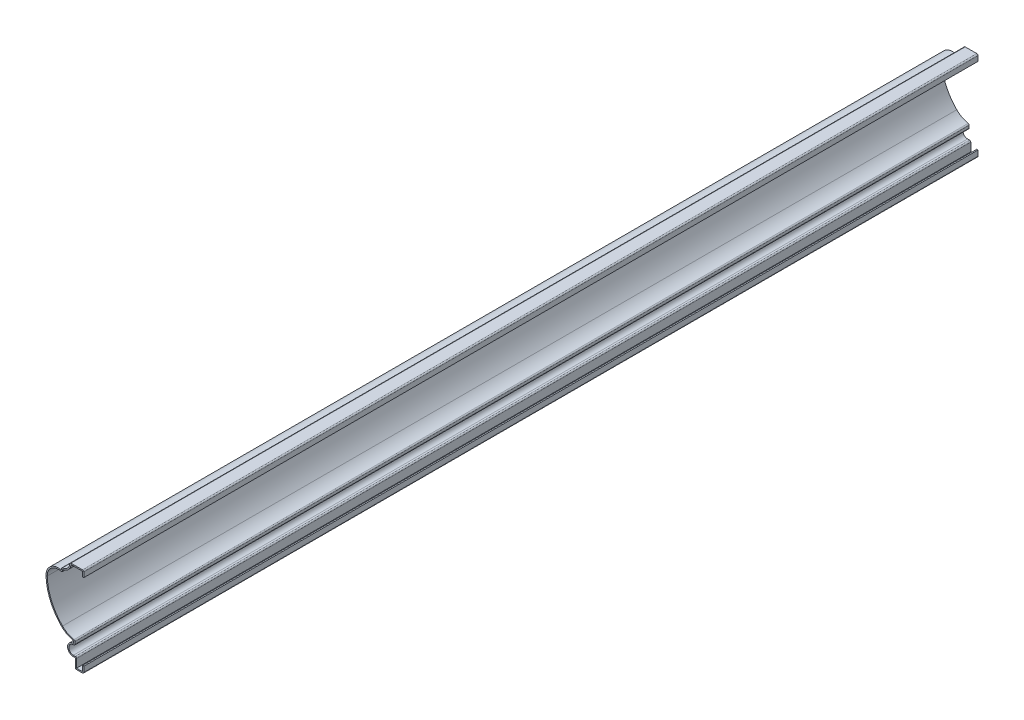
from build123d import *

# Parameters (mm, degrees)
EXTRUDE_THIN1_DEPTH = 920.75
FILLET1_R           = 1.27


with BuildPart() as part:
    # Sketch3 → Extrude-Thin1 (new body)
    with BuildSketch(Plane.XY):
        with BuildLine():
            Line((0, 78.978125), (0, 85.328125))
            Line((0, 85.328125), (-14.2875, 85.328125))
            ThreePointArc((-14.2875, 85.328125), (-16.844823917, 79.154198917), (-23.01875, 76.596875))
            Line((-23.01875, 76.596875), (-23.01875, 74.202381102))
            ThreePointArc((-23.01875, 74.202381102), (-34.102024757, 71.842921697), (-38.889371992, 61.572218972))
            ThreePointArc((-38.889371992, 61.572218972), (-34.427603857, 41.242325722), (-22.75075149, 24.012611469))
            ThreePointArc((-22.75075149, 24.012611469), (-17.030138602, 19.792593223), (-10.31875, 17.449256102))
            Line((-10.31875, 17.449256102), (-10.31875, 15.068006102))
            ThreePointArc((-10.31875, 15.068006102), (-16.665438104, 9.326672958), (-10.715625, 3.175))
            Line((-10.715625, 3.175), (-8.73125, 3.175))
            Line((-8.73125, 3.175), (-8.73125, -6.746875))
            Line((-8.73125, -6.746875), (0, -6.746875))
            Line((0, -6.746875), (0, 0))
            Line((0, 0), (-1.27, 0))
            Line((-1.27, 0), (-1.27, -5.476875))
            Line((-1.27, -5.476875), (-7.46125, -5.476875))
            Line((-7.46125, -5.476875), (-7.46125, 4.445))
            Line((-7.46125, 4.445), (-10.715625, 4.445))
            ThreePointArc((-10.715625, 4.445), (-15.321439486, 9.975552095), (-9.04875, 13.504560479))
            Line((-9.04875, 13.504560479), (-9.04875, 18.527286753))
            ThreePointArc((-9.04875, 18.527286753), (-15.97058408, 20.676234022), (-21.852725878, 24.910637081))
            ThreePointArc((-21.852725878, 24.910637081), (-33.260758622, 41.743696042), (-37.619809793, 61.605562972))
            ThreePointArc((-37.619809793, 61.605562972), (-32.636426474, 71.346888762), (-21.74875, 72.435942687))
            Line((-21.74875, 72.435942687), (-21.74875, 75.407837627))
            ThreePointArc((-21.74875, 75.407837627), (-15.946798305, 78.256173305), (-13.098462627, 84.058125))
            Line((-13.098462627, 84.058125), (-1.27, 84.058125))
            Line((-1.27, 84.058125), (-1.27, 78.978125))
            Line((-1.27, 78.978125), (0, 78.978125))
        make_face()
    extrude(amount=-EXTRUDE_THIN1_DEPTH)

    # Fillet1
    fillet1_edges = [part.edges().sort_by_distance(p)[0] for p in [
        (0, -6.746875, -460.375),
        (-8.73125, -6.746875, -460.375),
        (-23.01875, 76.596875, -460.375),
        (-14.2875, 85.328125, -460.375),
        (0, 85.328125, -460.375),
        (-21.74875, 72.435942687, -460.375),
        (-9.04875, 18.527286753, -460.375),
        (-9.04875, 13.504560479, -460.375),
        (-7.46125, 4.445, -460.375),
    ]]
    fillet(fillet1_edges, radius=FILLET1_R)


solid = part.part
